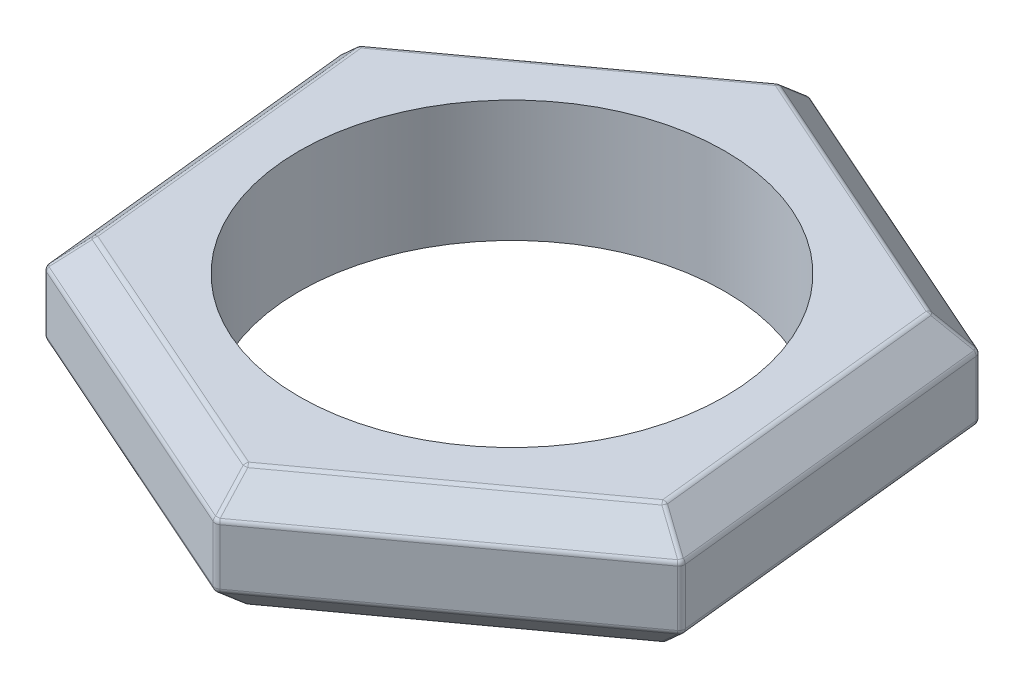
from build123d import *

# Parameters (mm, degrees)
SKETCH1_R      = 3.5
EXTRUDE1_DEPTH = 2
CHAMFER1_SIZE  = 0.5
CHAMFER2_SIZE  = 0.5
FILLET1_R      = 0.1


with BuildPart() as part:
    # Sketch1 → Extrude1 (new body)
    with BuildSketch(Plane(origin=(0, 0, 0), x_dir=(1, 0, 0), z_dir=(0, 1, 0))):
        Polygon((5.027952374, -2.229281258), (4.444590388, 3.239693856), (-0.583361985, 5.468975114), (-5.027952374, 2.229281258), (-4.444590388, -3.239693856), (0.583361985, -5.468975114), align=None)
        with Locations(Location((0, 0, 0), (0, 0, 270))):  # turned: the seam where the file's is
            Circle(SKETCH1_R, mode=Mode.SUBTRACT)
    extrude(amount=EXTRUDE1_DEPTH)

    # Chamfer1
    chamfer1_edges = [part.edges().sort_by_distance(p)[0] for p in [
        (1.930614202, 2, -4.354334485),
        (-2.80565718, 2, -3.849128186),
        (-4.736271381, 2, 0.505206299),
        (-1.930614202, 2, 4.354334485),
        (2.80565718, 2, 3.849128186),
        (4.736271381, 2, -0.505206299),
    ]]
    chamfer(chamfer1_edges, length=CHAMFER1_SIZE)

    # Chamfer2
    chamfer2_edges = [part.edges().sort_by_distance(p)[0] for p in [
        (-1.930614202, 0, 4.354334485),
        (-4.736271381, 0, 0.505206299),
        (-2.80565718, 0, -3.849128186),
        (1.930614202, 0, -4.354334485),
        (4.736271381, 0, -0.505206299),
        (2.80565718, 0, 3.849128186),
    ]]
    chamfer(chamfer2_edges, length=CHAMFER2_SIZE)

    # Fillet1
    fillet1_edges = [part.edges().sort_by_distance(p)[0] for p in [
        (2.511139556, 2, 3.445074514),
        (4.239091825, 2, -0.452173391),
        (1.727952269, 2, -3.897247905),
        (-2.511139556, 2, -3.445074514),
        (-4.239091825, 2, 0.452173391),
        (-1.727952269, 2, 3.897247905),
        (0.583361985, 1, 5.468975114),
        (-4.444590388, 1, 3.239693856),
        (-1.930614202, 1.5, 4.354334485),
        (-5.027952374, 1, -2.229281258),
        (-4.736271381, 1.5, 0.505206299),
        (-0.583361985, 1, -5.468975114),
        (-2.80565718, 1.5, -3.849128186),
        (4.444590388, 1, -3.239693856),
        (1.930614202, 1.5, -4.354334485),
        (5.027952374, 1, 2.229281258),
        (4.736271381, 1.5, -0.505206299),
        (2.80565718, 1.5, 3.849128186),
        (-0.552743422, 1.75, -5.181928363),
        (4.211309892, 1.75, -3.069654027),
        (-4.764053314, 1.75, -2.112274337),
        (4.764053314, 1.75, 2.112274337),
        (-4.211309892, 1.75, 3.069654027),
        (0.552743422, 1.75, 5.181928363),
        (-4.736271381, 0.5, 0.505206299),
        (-1.727952269, 0, 3.897247905),
        (2.511139556, 0, 3.445074514),
        (4.239091825, 0, -0.452173391),
        (1.727952269, 0, -3.897247905),
        (-2.511139556, 0, -3.445074514),
        (-4.239091825, 0, 0.452173391),
        (-2.80565718, 0.5, -3.849128186),
        (1.930614202, 0.5, -4.354334485),
        (4.736271381, 0.5, -0.505206299),
        (2.80565718, 0.5, 3.849128186),
        (-1.930614202, 0.5, 4.354334485),
        (4.211309892, 0.25, -3.069654027),
        (4.764053314, 0.25, 2.112274337),
        (-0.552743422, 0.25, -5.181928363),
        (0.552743422, 0.25, 5.181928363),
        (-4.764053314, 0.25, -2.112274337),
        (-4.211309892, 0.25, 3.069654027),
    ]]
    fillet(fillet1_edges, radius=FILLET1_R)


solid = part.part
